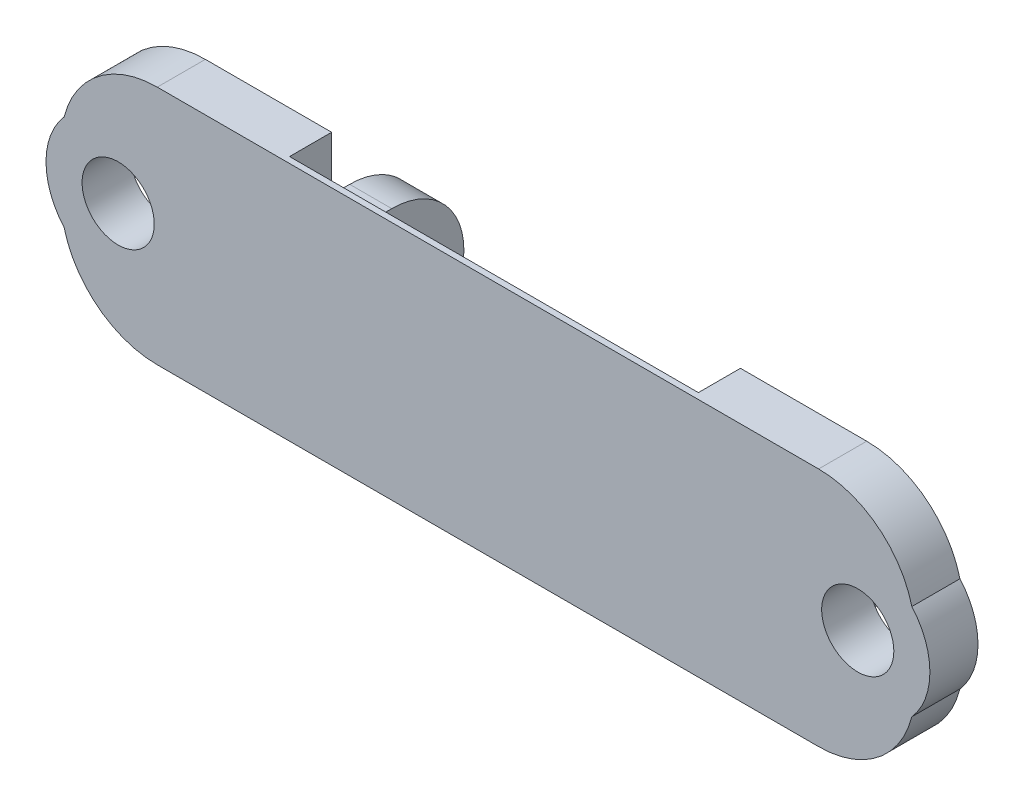
from build123d import *

# Parameters (mm, degrees)
SKETCH1_R             = 3
BOSS_EXTRUDE3_DEPTH   = 4
BOSS_EXTRUDE3_2_DEPTH = 4
SKETCH1_9_W           = 34
SKETCH1_9_H           = 20
BOSS_EXTRUDE4_DEPTH   = 2
CUT_EXTRUDE1_DEPTH    = 34
SKETCH3_R             = 3
BOSS_EXTRUDE5_DEPTH   = 3.5


with BuildPart() as part:
    # Sketch1 → Boss-Extrude3 (new body)
    with BuildSketch(Plane.XY):
        with BuildLine():
            ThreePointArc((0.246000737, 6.031372198), (3.088229566, 1.685373233), (8, 0))
            Line((8, 0), (18.5, 0))
            Line((18.5, 0), (18.5, 20))
            Line((18.5, 20), (8, 20))
            ThreePointArc((8, 20), (3.088229566, 18.314626767), (0.246000737, 13.968627802))
            ThreePointArc((0.246000737, 13.968627802), (-1.254, 10), (0.246000737, 6.031372198))
        make_face()
        with Locations((4.746, 10)):
            Circle(SKETCH1_R, mode=Mode.SUBTRACT)
    extrude(amount=-BOSS_EXTRUDE3_DEPTH)



with BuildPart() as body_2:
    # Sketch1 → Boss-Extrude3 2 (new body)
    with BuildSketch(Plane.XY):
        with BuildLine():
            Line((52.5, 20), (52.5, 0))
            Line((52.5, 0), (63, 0))
            ThreePointArc((63, 0), (67.911770434, 1.685373233), (70.753999263, 6.031372198))
            ThreePointArc((70.753999263, 6.031372198), (72.254, 10), (70.753999263, 13.968627802))
            ThreePointArc((70.753999263, 13.968627802), (67.911770434, 18.314626767), (63, 20))
            Line((63, 20), (52.5, 20))
        make_face()
        with Locations((66.254, 10)):
            Circle(SKETCH1_R, mode=Mode.SUBTRACT)
    extrude(amount=-BOSS_EXTRUDE3_2_DEPTH)


with BuildPart() as part_1:
    add(part.part)

    add(body_2.part)  # Boss-Extrude4 merges body 2
    # Sketch1_9 → Boss-Extrude4 (add)
    with BuildSketch(Plane.XY):
        with Locations((35.5, 10)):
            Rectangle(SKETCH1_9_W, SKETCH1_9_H)
    extrude(amount=-BOSS_EXTRUDE4_DEPTH)

    # Sketch2 → Cut-Extrude1 (cut)
    with BuildSketch(Plane(origin=(18.5, 0, 0), x_dir=(0, 0, -1), z_dir=(1, 0, 0))):
        Polygon((2, 20), (0.5, 20), (2, 7.70719), align=None)
    extrude(amount=CUT_EXTRUDE1_DEPTH, mode=Mode.SUBTRACT)

    # Sketch3 → Boss-Extrude5 (add)
    with BuildSketch(Plane(origin=(18.5, 0, 0), x_dir=(0, 0, -1), z_dir=(1, 0, 0))):
        with BuildLine():
            Line((4, 0), (9, 0))
            ThreePointArc((9, 0), (15, 6), (9, 12))
            Line((9, 12), (4, 12))
            Line((4, 12), (4, 0))
        make_face()
        with Locations((9, 6)):
            Circle(SKETCH3_R, mode=Mode.SUBTRACT)
    boss_extrude5 = extrude(amount=-BOSS_EXTRUDE5_DEPTH)

    # Mirror1: Boss-Extrude5 across plane
    add(boss_extrude5.mirror(Plane(origin=(35.5, 0, 0), x_dir=(0, 0, 1), z_dir=(1, 0, 0))))


solid = part_1.part
